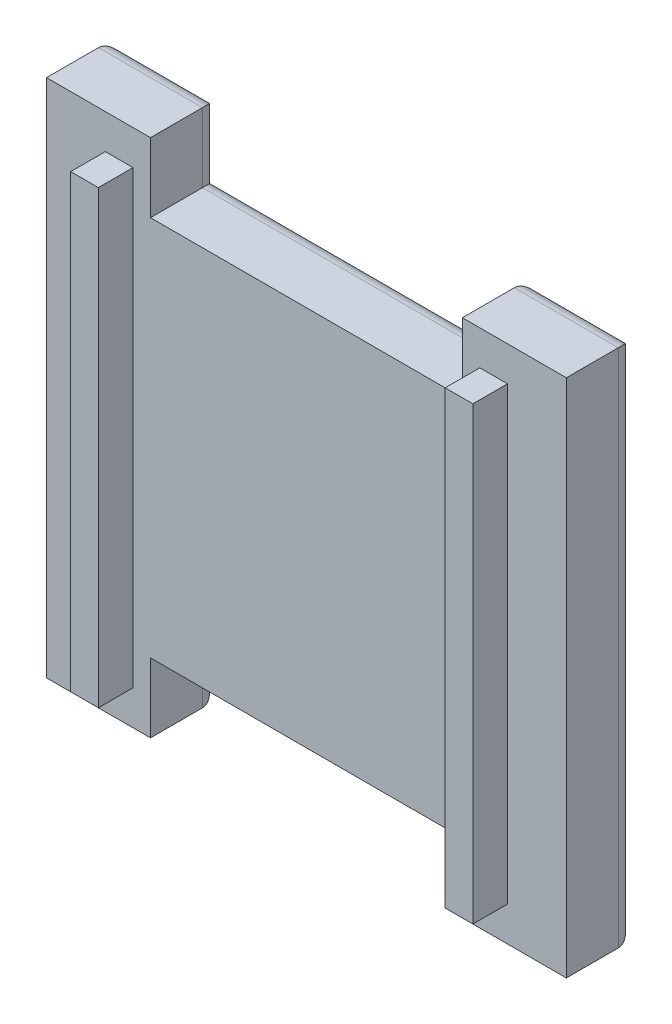
from build123d import *

# Parameters (mm, degrees)
SKETCH1_W           = 38.1
SKETCH1_H           = 38.1
BOSS_EXTRUDE1_DEPTH = 5.08
SKETCH5_W           = 2.032
SKETCH5_H           = 33.02
BOSS_EXTRUDE3_DEPTH = 2.54
SKETCH6_W           = 22.86
SKETCH6_H           = 5.08
CUT_EXTRUDE1_DEPTH  = 8.62
FILLET1_R           = 1.27


with BuildPart() as part:
    # Sketch1 → Boss-Extrude1 (new body)
    with BuildSketch(Plane.XY):
        with Locations((0.962710567, -6.301378254)):
            Rectangle(SKETCH1_W, SKETCH1_H)
    extrude(amount=BOSS_EXTRUDE1_DEPTH)

    # Sketch5 → Boss-Extrude3 (add)
    with BuildSketch(Plane.XY.offset(5.08)):
        with Locations((14.686710567, -6.301378254)):
            Rectangle(SKETCH5_W, SKETCH5_H)
        with Locations((-12.761289417, -6.301378254)):
            Rectangle(SKETCH5_W, SKETCH5_H)
    extrude(amount=BOSS_EXTRUDE3_DEPTH)

    # Sketch6 → Cut-Extrude1 (cut, through all)
    with BuildSketch(Plane(origin=(0, 0, 0), x_dir=(-1, 0, 0), z_dir=(0, 0, -1))):
        with Locations((-0.962710567, 10.208621746)):
            Rectangle(SKETCH6_W, SKETCH6_H)
        with Locations((-0.962710567, -22.811378254)):
            Rectangle(SKETCH6_W, SKETCH6_H)
    extrude(amount=-CUT_EXTRUDE1_DEPTH, mode=Mode.SUBTRACT)

    # Fillet1
    fillet1_edges = [part.edges().sort_by_distance(p)[0] for p in [
        (-14.277289433, 12.748621746, 0),
        (16.202710567, -25.351378254, 0),
        (16.202710567, 12.748621746, 0),
        (20.012710567, -6.301378254, 0),
        (-10.467289433, 10.208621746, 0),
        (12.392710567, 10.208621746, 0),
        (0.962710567, 7.668621746, 0),
        (-14.277289433, -25.351378254, 0),
        (-18.087289433, -6.301378254, 0),
        (12.392710567, -22.811378254, 0),
        (-10.467289433, -22.811378254, 0),
        (0.962710567, -20.271378254, 0),
    ]]
    fillet(fillet1_edges, radius=FILLET1_R)


solid = part.part
